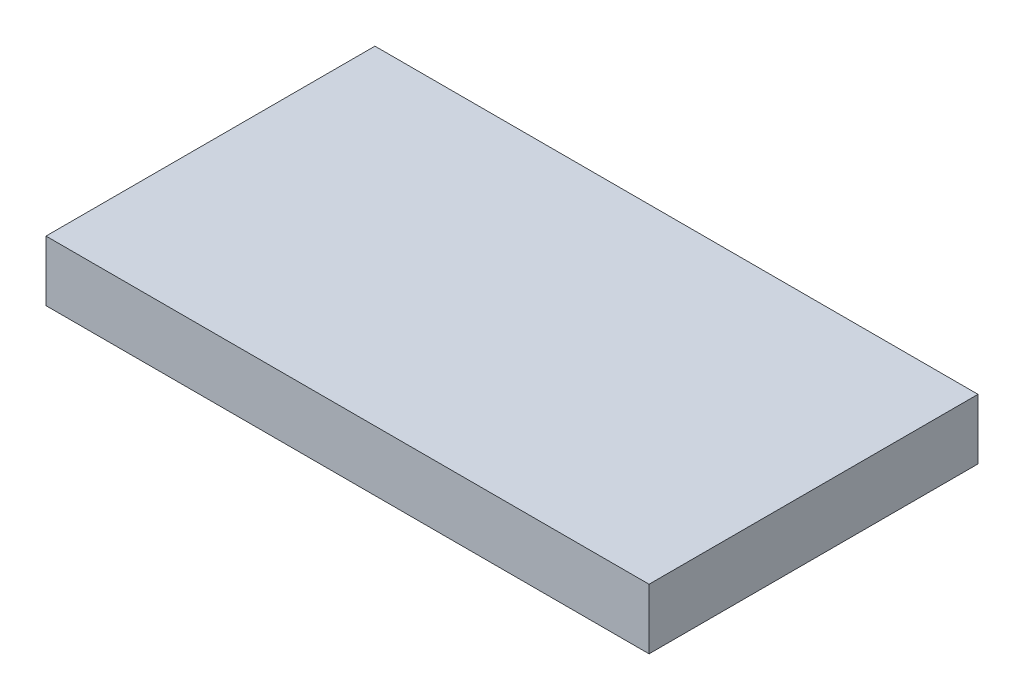
from build123d import *

# Parameters (mm, degrees)
SKETCH1_W           = 16.5
SKETCH1_H           = 9
BOSS_EXTRUDE1_DEPTH = 1.65


with BuildPart() as part:
    # Sketch1 → Boss-Extrude1 (new body)
    with BuildSketch(Plane(origin=(0, 0, 0), x_dir=(1, 0, 0), z_dir=(0, 1, 0))):
        Rectangle(SKETCH1_W, SKETCH1_H)
    extrude(amount=BOSS_EXTRUDE1_DEPTH)


solid = part.part
